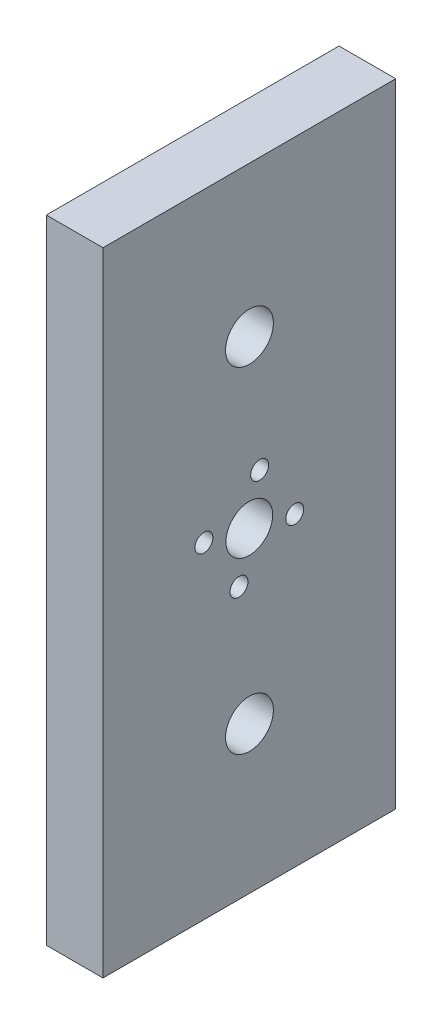
from build123d import *

# Parameters (mm, degrees)
SKETCH2_W           = 51.670795736
SKETCH2_H           = 111.629965862
BOSS_EXTRUDE1_DEPTH = 10
SKETCH3_R           = 4.225
SKETCH3_R_2         = 4.1275
CUT_EXTRUDE1_DEPTH  = 11
SKETCH5_R           = 1.5875
CUT_EXTRUDE2_DEPTH  = 11


with BuildPart() as part:
    # Sketch2 → Boss-Extrude1 (new body)
    with BuildSketch(Plane(origin=(0, 0, 0), x_dir=(0, 0, -1), z_dir=(1, 0, 0))):
        with Locations((416.961058265, -489.879931508)):
            Rectangle(SKETCH2_W, SKETCH2_H)
    extrude(amount=BOSS_EXTRUDE1_DEPTH)

    # Sketch3 → Cut-Extrude1 (cut, through all)
    with BuildSketch(Plane(origin=(10, 0, 0), x_dir=(0, 0, -1), z_dir=(1, 0, 0))):
        with Locations((416.982623845, -460.578730032)):
            Circle(SKETCH3_R)
        with Locations((416.982623845, -519.760730032)):
            Circle(SKETCH3_R)
        with Locations((416.961058265, -489.879931508)):
            Circle(SKETCH3_R_2)
    extrude(amount=-CUT_EXTRUDE1_DEPTH, mode=Mode.SUBTRACT)

    # Sketch5 → Cut-Extrude2 (cut, through all)
    with BuildSketch(Plane(origin=(10, 0, 0), x_dir=(0, 0, -1), z_dir=(1, 0, 0))):
        with Locations((418.78573561, -481.859784241)):
            Circle(SKETCH5_R)
        with Locations((424.981126269, -491.704497776)):
            Circle(SKETCH5_R)
        with Locations((415.136412734, -497.899888435)):
            Circle(SKETCH5_R)
        with Locations((408.941022075, -488.0551749)):
            Circle(SKETCH5_R)
    extrude(amount=-CUT_EXTRUDE2_DEPTH, mode=Mode.SUBTRACT)


solid = part.part
